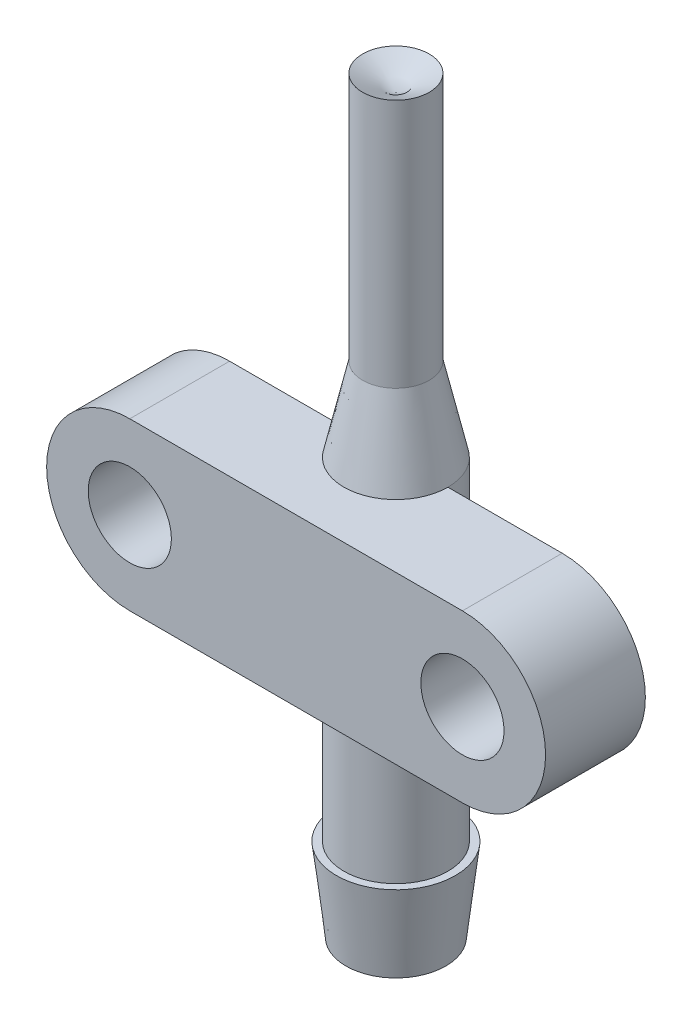
from build123d import *

# Parameters (mm, degrees)
SKETCH2_R           = 2.5
BOSS_EXTRUDE1_DEPTH = 6
SKETCH3_R           = 1.75
CUT_EXTRUDE1_DEPTH  = 25


with BuildPart() as part:
    # Sketch1 → Revolve1 (revolve)
    with BuildSketch(Plane.XY):
        Polygon((2, 30), (3.125, 25), (3.125, 5), (3.575, 5), (3, 0), (1.75, 0), (1.75, 25), (1, 30), (1, 40), (0, 40), (0, 44), (2, 45), align=None)
    revolve(axis=Axis((0, 0, 0), (0, 1, 0)))


with BuildPart() as body_2:
    # Sketch2 → Boss-Extrude1 (new body)
    with BuildSketch(Plane.XY):
        with BuildLine():
            Line((-10, 25), (10, 25))
            ThreePointArc((10, 25), (15, 20), (10, 15))
            Line((10, 15), (-10, 15))
            ThreePointArc((-10, 15), (-15, 20), (-10, 25))
        make_face()
        with Locations((-10, 20)):
            Circle(SKETCH2_R, mode=Mode.SUBTRACT)
        with Locations((10, 20)):
            Circle(SKETCH2_R, mode=Mode.SUBTRACT)
    extrude(amount=BOSS_EXTRUDE1_DEPTH)

    # Sketch3 → Cut-Extrude1 (cut)
    with BuildSketch(Plane.XZ):
        Circle(SKETCH3_R)
    extrude(amount=-CUT_EXTRUDE1_DEPTH, mode=Mode.SUBTRACT)


solid = Compound([part.part, body_2.part])
